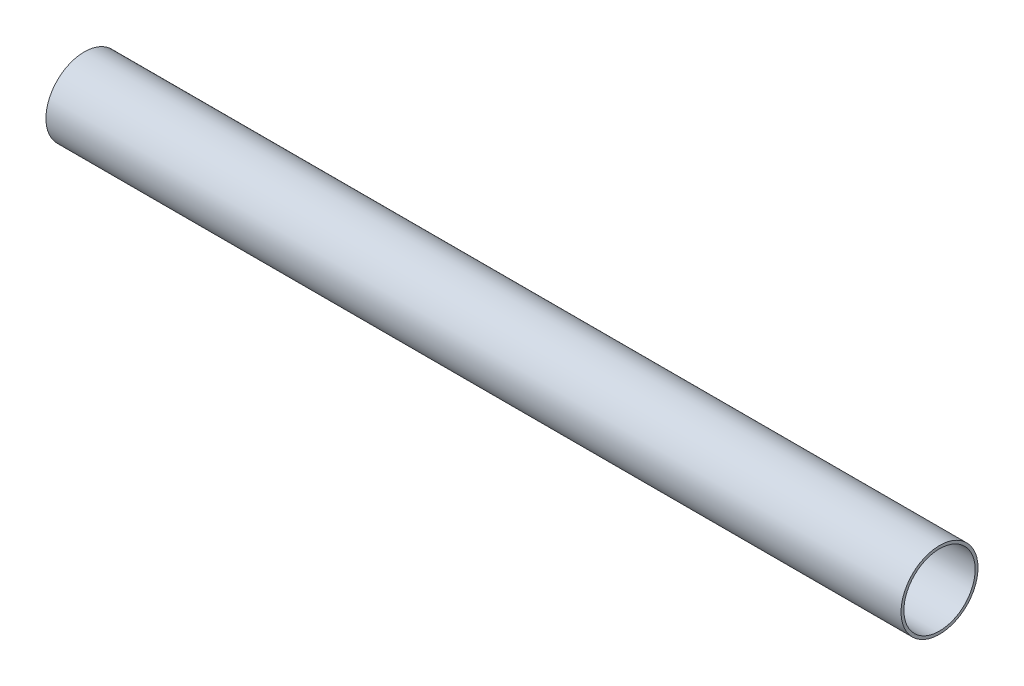
from build123d import *

# Parameters (mm, degrees)
SWEEP_THIN1_PROFILE_R   = 13.5
SWEEP_THIN1_PROFILE_R_2 = 12.5


with BuildPart() as part:
    # Sweep-Thin1: sweep along a curve in space
    with BuildLine() as sweep_thin1_path:
        Line((0, 0, 0), (300, 0, 0))
    # Sweep-Thin1 profile (on start of the path) → Sweep-Thin1 (sweep)
    with BuildSketch(Plane(origin=(0, 0, 0), x_dir=(0, 0, 1), z_dir=(1, 0, 0))):
        Circle(SWEEP_THIN1_PROFILE_R)
        Circle(SWEEP_THIN1_PROFILE_R_2, mode=Mode.SUBTRACT)
    sweep(path=sweep_thin1_path.line)


solid = part.part
